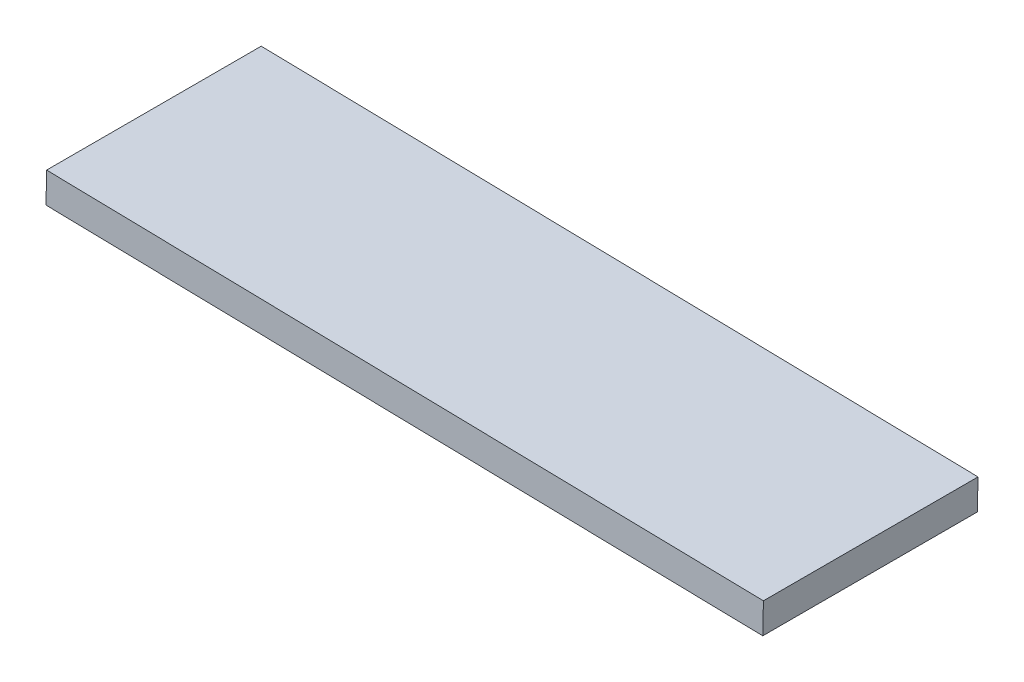
from build123d import *

# Parameters (mm, degrees)
BOSS_EXTRUDE1_DEPTH = 35


with BuildPart() as part:
    # Sketch4 → Boss-Extrude1 (new body)
    with BuildSketch(Plane(origin=(11.947136755, 45.550168558, 0), x_dir=(0.967281961, -0.253703778, 0), z_dir=(0, 0, 1))):
        Polygon((-78.116920089, 415.287804625), (-191.804047123, 387.937900462), (-192.973539508, 392.799205592), (-79.286412474, 420.149109755), align=None)
    extrude(amount=BOSS_EXTRUDE1_DEPTH)


solid = part.part
